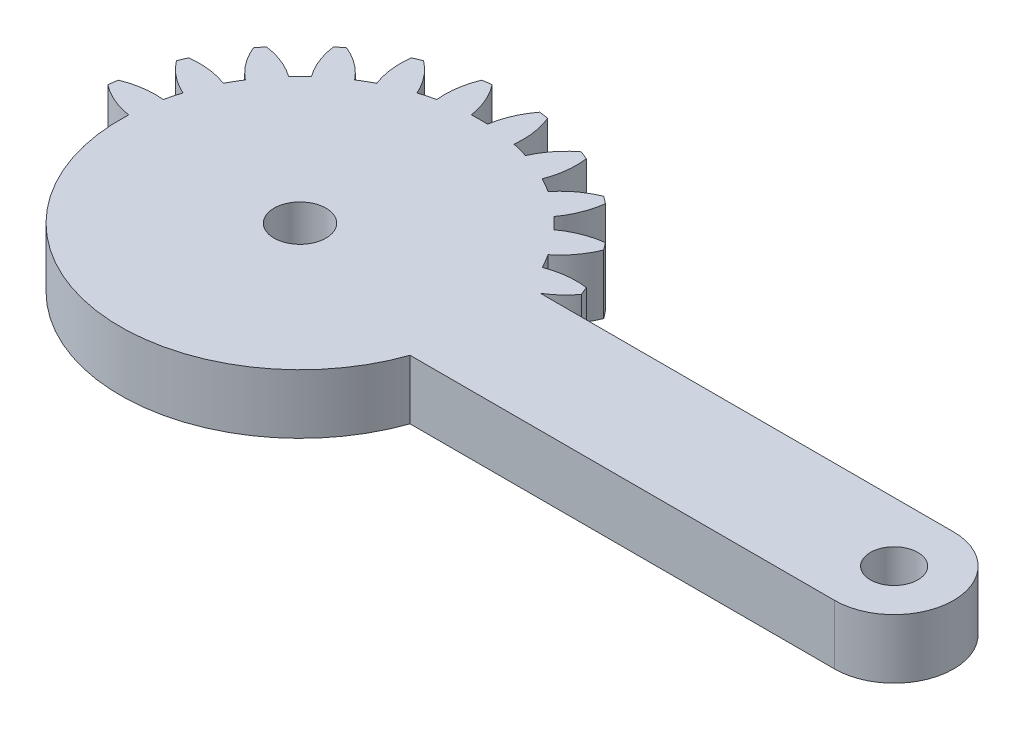
from build123d import *

# Parameters (mm, degrees)
SKETCH1_R           = 1.75
SKETCH1_R_2         = 1.6
BOSS_EXTRUDE1_DEPTH = 4
CUT_EXTRUDE1_DEPTH  = 10


with BuildPart() as part:
    # Sketch1 → Boss-Extrude1 (new body)
    with BuildSketch(Plane(origin=(0, 0, 0), x_dir=(1, 0, 0), z_dir=(0, 1, 0))):
        with BuildLine():
            Line((29.893657446, 4), (2.081641936, 4))
            ThreePointArc((2.081641936, 4), (2.861028333, 4.588201733), (3.521749436, 5.30713988))
            ThreePointArc((3.521749436, 5.30713988), (3.405395609, 5.596745198), (3.282888305, 5.883801663))
            ThreePointArc((3.282888305, 5.883801663), (1.93527598, 5.894040025), (0.627094961, 5.57027124))
            ThreePointArc((0.627094961, 5.57027124), (0.366286148, 6.046375), (0.084372603, 6.510293938))
            ThreePointArc((0.084372603, 6.510293938), (1.018855105, 7.48132754), (1.683794586, 8.65351323))
            ThreePointArc((1.683794586, 8.65351323), (1.496450048, 8.903135899), (1.303821399, 9.148703928))
            ThreePointArc((1.303821399, 9.148703928), (-0.000522033, 8.809805691), (-1.180330337, 8.158486898))
            ThreePointArc((-1.180330337, 8.158486898), (-1.555477026, 8.550865528), (-1.947855656, 8.926012217))
            ThreePointArc((-1.947855656, 8.926012217), (-1.296536862, 10.105820521), (-0.957638625, 11.410163953))
            ThreePointArc((-0.957638625, 11.410163953), (-1.203206655, 11.602792602), (-1.452829324, 11.79013714))
            ThreePointArc((-1.452829324, 11.79013714), (-2.625015014, 11.125197659), (-3.596048616, 10.190715157))
            ThreePointArc((-3.596048616, 10.190715157), (-4.059967554, 10.472628702), (-4.536071314, 10.733437515))
            ThreePointArc((-4.536071314, 10.733437515), (-4.212302529, 12.041618533), (-4.222540891, 13.389230859))
            ThreePointArc((-4.222540891, 13.389230859), (-4.509597355, 13.511738163), (-4.799202674, 13.62809199))
            ThreePointArc((-4.799202674, 13.62809199), (-5.759348103, 12.682425791), (-6.455432668, 11.528463019))
            ThreePointArc((-6.455432668, 11.528463019), (-6.976508546, 11.680699536), (-7.503891752, 11.809396783))
            ThreePointArc((-7.503891752, 11.809396783), (-7.529737283, 13.156800143), (-7.888414517, 14.455843809))
            ThreePointArc((-7.888414517, 14.455843809), (-8.197396993, 14.499881098), (-8.507248835, 14.537314892))
            ThreePointArc((-8.507248835, 14.537314892), (-9.18992168, 13.375367565), (-9.563620196, 12.080565177))
            ThreePointArc((-9.563620196, 12.080565177), (-10.106342554, 12.09275), (-10.649064912, 12.080565177))
            ThreePointArc((-10.649064912, 12.080565177), (-11.022763428, 13.375367565), (-11.705436272, 14.537314892))
            ThreePointArc((-11.705436272, 14.537314892), (-12.015288115, 14.499881098), (-12.324270591, 14.455843809))
            ThreePointArc((-12.324270591, 14.455843809), (-12.682947825, 13.156800143), (-12.708793355, 11.809396783))
            ThreePointArc((-12.708793355, 11.809396783), (-13.236176561, 11.680699536), (-13.757252439, 11.528463019))
            ThreePointArc((-13.757252439, 11.528463019), (-14.453337005, 12.682425791), (-15.413482434, 13.62809199))
            ThreePointArc((-15.413482434, 13.62809199), (-15.703087752, 13.511738163), (-15.990144217, 13.389230859))
            ThreePointArc((-15.990144217, 13.389230859), (-16.000382579, 12.041618533), (-15.676613793, 10.733437515))
            ThreePointArc((-15.676613793, 10.733437515), (-16.152717554, 10.472628702), (-16.616636492, 10.190715157))
            ThreePointArc((-16.616636492, 10.190715157), (-17.587670094, 11.125197659), (-18.759855783, 11.79013714))
            ThreePointArc((-18.759855783, 11.79013714), (-19.009478453, 11.602792602), (-19.255046482, 11.410163953))
            ThreePointArc((-19.255046482, 11.410163953), (-18.916148245, 10.105820521), (-18.264829452, 8.926012217))
            ThreePointArc((-18.264829452, 8.926012217), (-18.657208082, 8.550865528), (-19.032354771, 8.158486898))
            ThreePointArc((-19.032354771, 8.158486898), (-20.212163074, 8.809805691), (-21.516506507, 9.148703928))
            ThreePointArc((-21.516506507, 9.148703928), (-21.709135156, 8.903135899), (-21.896479694, 8.65351323))
            ThreePointArc((-21.896479694, 8.65351323), (-21.231540213, 7.48132754), (-20.297057711, 6.510293938))
            ThreePointArc((-20.297057711, 6.510293938), (-20.578971255, 6.046375), (-20.839780068, 5.57027124))
            ThreePointArc((-20.839780068, 5.57027124), (-22.147961087, 5.894040025), (-23.495573413, 5.883801663))
            ThreePointArc((-23.495573413, 5.883801663), (-23.618080717, 5.596745198), (-23.734434544, 5.30713988))
            ThreePointArc((-23.734434544, 5.30713988), (-22.788768345, 4.346994451), (-21.634805572, 3.650909885))
            ThreePointArc((-21.634805572, 3.650909885), (-21.78704209, 3.129834008), (-21.915739337, 2.602450802))
            ThreePointArc((-21.915739337, 2.602450802), (-23.263142697, 2.576605271), (-24.562186363, 2.217928037))
            ThreePointArc((-24.562186363, 2.217928037), (-24.606223651, 1.908945561), (-24.643657446, 1.599093719))
            ThreePointArc((-24.643657446, 1.599093719), (-23.481710119, 0.916420874), (-22.186907731, 0.542722358))
            ThreePointArc((-22.186907731, 0.542722358), (-22.199092554, 0), (-22.186907731, -0.542722358))
            ThreePointArc((-22.186907731, -0.542722358), (-23.481710119, -0.916420874), (-24.643657446, -1.599093719))
            ThreePointArc((-24.643657446, -1.599093719), (-24.606223651, -1.908945561), (-24.562186363, -2.217928037))
            ThreePointArc((-24.562186363, -2.217928037), (-23.263142697, -2.576605271), (-21.915739337, -2.602450802))
            ThreePointArc((-21.915739337, -2.602450802), (-21.78704209, -3.129834008), (-21.634805572, -3.650909885))
            ThreePointArc((-21.634805572, -3.650909885), (-22.788768345, -4.346994451), (-23.734434544, -5.30713988))
            ThreePointArc((-23.734434544, -5.30713988), (-23.618080717, -5.596745198), (-23.495573413, -5.883801663))
            ThreePointArc((-23.495573413, -5.883801663), (-22.147961087, -5.894040025), (-20.839780068, -5.57027124))
            ThreePointArc((-20.839780068, -5.57027124), (-20.578971255, -6.046375), (-20.297057711, -6.510293938))
            ThreePointArc((-20.297057711, -6.510293938), (-21.231540213, -7.48132754), (-21.896479694, -8.65351323))
            ThreePointArc((-21.896479694, -8.65351323), (-21.709135156, -8.903135899), (-21.516506507, -9.148703928))
            ThreePointArc((-21.516506507, -9.148703928), (-20.212163074, -8.809805691), (-19.032354771, -8.158486898))
            ThreePointArc((-19.032354771, -8.158486898), (-18.657208082, -8.550865528), (-18.264829452, -8.926012217))
            ThreePointArc((-18.264829452, -8.926012217), (-18.916148245, -10.105820521), (-19.255046482, -11.410163953))
            ThreePointArc((-19.255046482, -11.410163953), (-19.009478453, -11.602792602), (-18.759855783, -11.79013714))
            ThreePointArc((-18.759855783, -11.79013714), (-17.587670094, -11.125197659), (-16.616636492, -10.190715157))
            ThreePointArc((-16.616636492, -10.190715157), (-16.152717554, -10.472628702), (-15.676613793, -10.733437515))
            ThreePointArc((-15.676613793, -10.733437515), (-16.000382579, -12.041618533), (-15.990144217, -13.389230859))
            ThreePointArc((-15.990144217, -13.389230859), (-15.703087752, -13.511738163), (-15.413482434, -13.62809199))
            ThreePointArc((-15.413482434, -13.62809199), (-14.453337005, -12.682425791), (-13.757252439, -11.528463019))
            ThreePointArc((-13.757252439, -11.528463019), (-13.236176561, -11.680699536), (-12.708793355, -11.809396783))
            ThreePointArc((-12.708793355, -11.809396783), (-12.682947825, -13.156800143), (-12.324270591, -14.455843809))
            ThreePointArc((-12.324270591, -14.455843809), (-12.015288115, -14.499881098), (-11.705436272, -14.537314892))
            ThreePointArc((-11.705436272, -14.537314892), (-11.022763428, -13.375367565), (-10.649064912, -12.080565177))
            ThreePointArc((-10.649064912, -12.080565177), (-10.106342554, -12.09275), (-9.563620196, -12.080565177))
            ThreePointArc((-9.563620196, -12.080565177), (-9.18992168, -13.375367565), (-8.507248835, -14.537314892))
            ThreePointArc((-8.507248835, -14.537314892), (-8.197396993, -14.499881098), (-7.888414517, -14.455843809))
            ThreePointArc((-7.888414517, -14.455843809), (-7.529737283, -13.156800143), (-7.503891752, -11.809396783))
            ThreePointArc((-7.503891752, -11.809396783), (-6.976508546, -11.680699536), (-6.455432668, -11.528463019))
            ThreePointArc((-6.455432668, -11.528463019), (-5.759348103, -12.682425791), (-4.799202674, -13.62809199))
            ThreePointArc((-4.799202674, -13.62809199), (-4.509597355, -13.511738163), (-4.222540891, -13.389230859))
            ThreePointArc((-4.222540891, -13.389230859), (-4.212302529, -12.041618533), (-4.536071314, -10.733437515))
            ThreePointArc((-4.536071314, -10.733437515), (-4.059967554, -10.472628702), (-3.596048616, -10.190715157))
            ThreePointArc((-3.596048616, -10.190715157), (-2.625015014, -11.125197659), (-1.452829324, -11.79013714))
            ThreePointArc((-1.452829324, -11.79013714), (-1.203206655, -11.602792602), (-0.957638625, -11.410163953))
            ThreePointArc((-0.957638625, -11.410163953), (-1.296536862, -10.105820521), (-1.947855656, -8.926012217))
            ThreePointArc((-1.947855656, -8.926012217), (-1.555477026, -8.550865528), (-1.180330337, -8.158486898))
            ThreePointArc((-1.180330337, -8.158486898), (-0.000522033, -8.809805691), (1.303821399, -9.148703928))
            ThreePointArc((1.303821399, -9.148703928), (1.496450048, -8.903135899), (1.683794586, -8.65351323))
            ThreePointArc((1.683794586, -8.65351323), (1.018855105, -7.48132754), (0.084372603, -6.510293938))
            ThreePointArc((0.084372603, -6.510293938), (0.366286148, -6.046375), (0.627094961, -5.57027124))
            ThreePointArc((0.627094961, -5.57027124), (1.93527598, -5.894040025), (3.282888305, -5.883801663))
            ThreePointArc((3.282888305, -5.883801663), (3.405395609, -5.596745198), (3.521749436, -5.30713988))
            ThreePointArc((3.521749436, -5.30713988), (2.861028333, -4.588201733), (2.081641936, -4))
            Line((2.081641936, -4), (29.893657446, -4))
            ThreePointArc((29.893657446, -4), (33.893657446, 0), (29.893657446, 4))
        make_face()
        with Locations((-10.106342554, 0)):
            Circle(SKETCH1_R, mode=Mode.SUBTRACT)
        with Locations((29.893657446, 0)):
            Circle(SKETCH1_R_2, mode=Mode.SUBTRACT)
    extrude(amount=BOSS_EXTRUDE1_DEPTH)

    # Sketch2 → Cut-Extrude1 (cut)
    with BuildSketch(Plane(origin=(0, 4, 0), x_dir=(1, 0, 0), z_dir=(0, 1, 0))):
        with BuildLine():
            ThreePointArc((-24.562186363, -2.217928037), (-23.263142697, -2.576605271), (-21.915739337, -2.602450802))
            ThreePointArc((-21.915739337, -2.602450802), (-22.095637401, -1.578420611), (-22.186907731, -0.542722358))
            ThreePointArc((-22.186907731, -0.542722358), (-23.481710119, -0.916420874), (-24.643657446, -1.599093719))
            ThreePointArc((-24.643657446, -1.599093719), (-24.606223651, -1.908945561), (-24.562186363, -2.217928037))
        make_face()
        with BuildLine():
            ThreePointArc((-23.495573413, -5.883801663), (-22.147961087, -5.894040025), (-20.839780068, -5.57027124))
            ThreePointArc((-20.839780068, -5.57027124), (-21.278586771, -4.627695077), (-21.634805572, -3.650909885))
            ThreePointArc((-21.634805572, -3.650909885), (-22.788768345, -4.346994451), (-23.734434544, -5.30713988))
            ThreePointArc((-23.734434544, -5.30713988), (-23.618080717, -5.596745198), (-23.495573413, -5.883801663))
        make_face()
        with BuildLine():
            ThreePointArc((-21.516506507, -9.148703928), (-20.212163074, -8.809805691), (-19.032354771, -8.158486898))
            ThreePointArc((-19.032354771, -8.158486898), (-19.70016616, -7.361599771), (-20.297057711, -6.510293938))
            ThreePointArc((-20.297057711, -6.510293938), (-21.231540213, -7.48132754), (-21.896479694, -8.65351323))
            ThreePointArc((-21.896479694, -8.65351323), (-21.709135156, -8.903135899), (-21.516506507, -9.148703928))
        make_face()
        with BuildLine():
            ThreePointArc((-18.759855783, -11.79013714), (-17.587670094, -11.125197659), (-16.616636492, -10.190715157))
            ThreePointArc((-16.616636492, -10.190715157), (-17.467942324, -9.593823606), (-18.264829452, -8.926012217))
            ThreePointArc((-18.264829452, -8.926012217), (-18.916148245, -10.105820521), (-19.255046482, -11.410163953))
            ThreePointArc((-19.255046482, -11.410163953), (-19.009478453, -11.602792602), (-18.759855783, -11.79013714))
        make_face()
        with BuildLine():
            ThreePointArc((-15.413482434, -13.62809199), (-14.453337005, -12.682425791), (-13.757252439, -11.528463019))
            ThreePointArc((-13.757252439, -11.528463019), (-14.734037631, -11.172244217), (-15.676613793, -10.733437515))
            ThreePointArc((-15.676613793, -10.733437515), (-16.000382579, -12.041618533), (-15.990144217, -13.389230859))
            ThreePointArc((-15.990144217, -13.389230859), (-15.703087752, -13.511738163), (-15.413482434, -13.62809199))
        make_face()
        with BuildLine():
            ThreePointArc((-11.705436272, -14.537314892), (-11.022763428, -13.375367565), (-10.649064912, -12.080565177))
            ThreePointArc((-10.649064912, -12.080565177), (-11.684763165, -11.989294847), (-12.708793355, -11.809396783))
            ThreePointArc((-12.708793355, -11.809396783), (-12.682947825, -13.156800143), (-12.324270591, -14.455843809))
            ThreePointArc((-12.324270591, -14.455843809), (-12.015288115, -14.499881098), (-11.705436272, -14.537314892))
        make_face()
        with BuildLine():
            ThreePointArc((-7.888414517, -14.455843809), (-7.529737283, -13.156800143), (-7.503891752, -11.809396783))
            ThreePointArc((-7.503891752, -11.809396783), (-8.527921943, -11.989294847), (-9.563620196, -12.080565177))
            ThreePointArc((-9.563620196, -12.080565177), (-9.18992168, -13.375367565), (-8.507248835, -14.537314892))
            ThreePointArc((-8.507248835, -14.537314892), (-8.197396993, -14.499881098), (-7.888414517, -14.455843809))
        make_face()
        with BuildLine():
            ThreePointArc((-4.222540891, -13.389230859), (-4.212302529, -12.041618533), (-4.536071314, -10.733437515))
            ThreePointArc((-4.536071314, -10.733437515), (-5.478647477, -11.172244217), (-6.455432668, -11.528463019))
            ThreePointArc((-6.455432668, -11.528463019), (-5.759348103, -12.682425791), (-4.799202674, -13.62809199))
            ThreePointArc((-4.799202674, -13.62809199), (-4.509597355, -13.511738163), (-4.222540891, -13.389230859))
        make_face()
        with BuildLine():
            ThreePointArc((-0.957638625, -11.410163953), (-1.296536862, -10.105820521), (-1.947855656, -8.926012217))
            ThreePointArc((-1.947855656, -8.926012217), (-2.744742783, -9.593823606), (-3.596048616, -10.190715157))
            ThreePointArc((-3.596048616, -10.190715157), (-2.625015014, -11.125197659), (-1.452829324, -11.79013714))
            ThreePointArc((-1.452829324, -11.79013714), (-1.203206655, -11.602792602), (-0.957638625, -11.410163953))
        make_face()
        with BuildLine():
            ThreePointArc((1.683794586, -8.65351323), (1.018855105, -7.48132754), (0.084372603, -6.510293938))
            ThreePointArc((0.084372603, -6.510293938), (-0.512518948, -7.361599771), (-1.180330337, -8.158486898))
            ThreePointArc((-1.180330337, -8.158486898), (-0.000522033, -8.809805691), (1.303821399, -9.148703928))
            ThreePointArc((1.303821399, -9.148703928), (1.496450048, -8.903135899), (1.683794586, -8.65351323))
        make_face()
        with BuildLine():
            ThreePointArc((3.521749436, -5.30713988), (2.861028333, -4.588201733), (2.081641936, -4))
            Line((2.081641936, -4), (1.305695063, -4))
            ThreePointArc((1.305695063, -4), (0.994195953, -4.797149927), (0.627094961, -5.57027124))
            ThreePointArc((0.627094961, -5.57027124), (1.93527598, -5.894040025), (3.282888305, -5.883801663))
            ThreePointArc((3.282888305, -5.883801663), (3.405395609, -5.596745198), (3.521749436, -5.30713988))
        make_face()
    extrude(amount=-CUT_EXTRUDE1_DEPTH, mode=Mode.SUBTRACT)


solid = part.part
